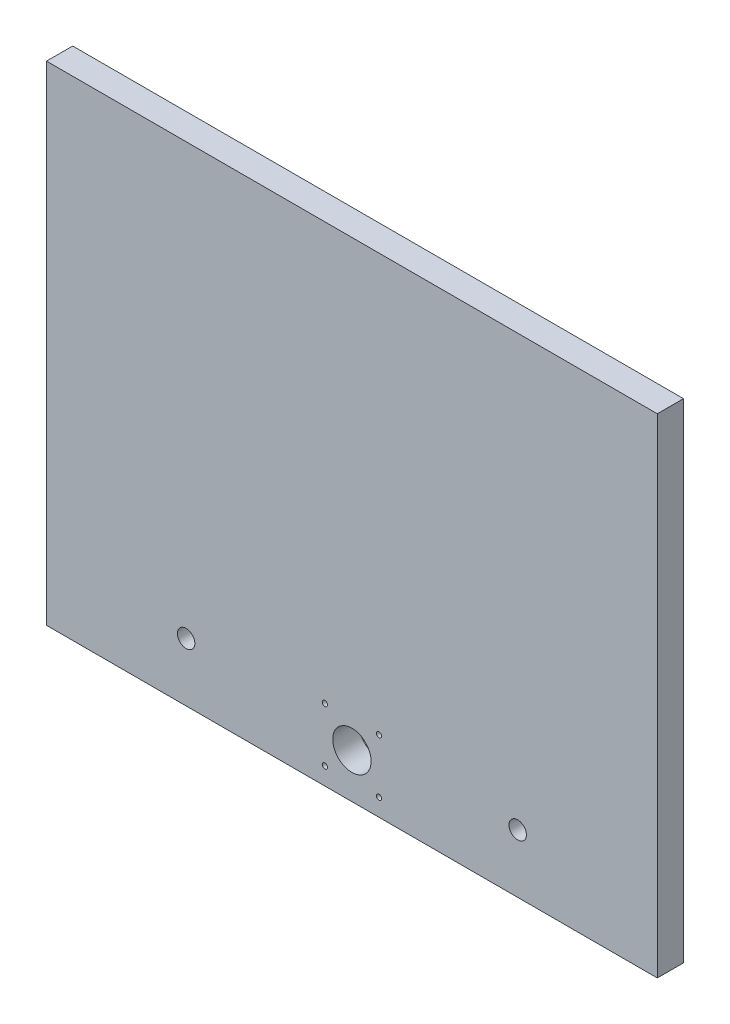
from build123d import *

# Parameters (mm, degrees)
SKETCH3_W           = 350
SKETCH3_H           = 280
SKETCH3_R           = 1.5
SKETCH3_R_2         = 11
SKETCH3_R_3         = 5
BOSS_EXTRUDE3_DEPTH = 15


with BuildPart() as part:
    # Sketch3 → Boss-Extrude3 (new body)
    with BuildSketch(Plane.XY):
        with Locations((369.918861249, 211.697453917)):
            Rectangle(SKETCH3_W, SKETCH3_H)
        with Locations((354.418861249, 112.697453917)):
            Circle(SKETCH3_R, mode=Mode.SUBTRACT)
        with Locations((385.418861249, 112.697453917)):
            Circle(SKETCH3_R, mode=Mode.SUBTRACT)
        with Locations((354.418861249, 81.697453917)):
            Circle(SKETCH3_R, mode=Mode.SUBTRACT)
        with Locations((385.418861249, 81.697453917)):
            Circle(SKETCH3_R, mode=Mode.SUBTRACT)
        with Locations((369.918861249, 97.197453917)):
            Circle(SKETCH3_R_2, mode=Mode.SUBTRACT)
        with Locations((274.918861249, 105.197453917)):
            Circle(SKETCH3_R_3, mode=Mode.SUBTRACT)
        with Locations((464.918861249, 105.197453917)):
            Circle(SKETCH3_R_3, mode=Mode.SUBTRACT)
    extrude(amount=BOSS_EXTRUDE3_DEPTH)


solid = part.part
